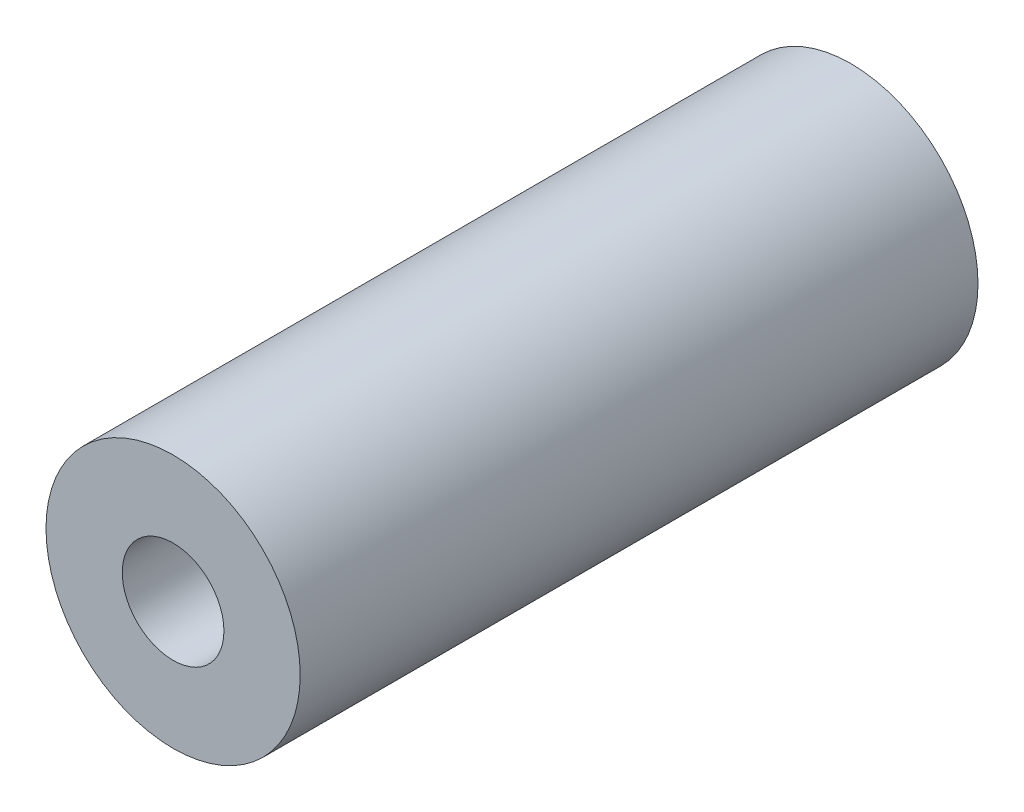
from build123d import *

# Parameters (mm, degrees)
SKETCH1_R           = 7.5
SKETCH1_R_2         = 3
BOSS_EXTRUDE1_DEPTH = 40


with BuildPart() as part:
    # Sketch1 → Boss-Extrude1 (new body)
    with BuildSketch(Plane.XY):
        Circle(SKETCH1_R)
        Circle(SKETCH1_R_2, mode=Mode.SUBTRACT)
    extrude(amount=BOSS_EXTRUDE1_DEPTH)


solid = part.part
